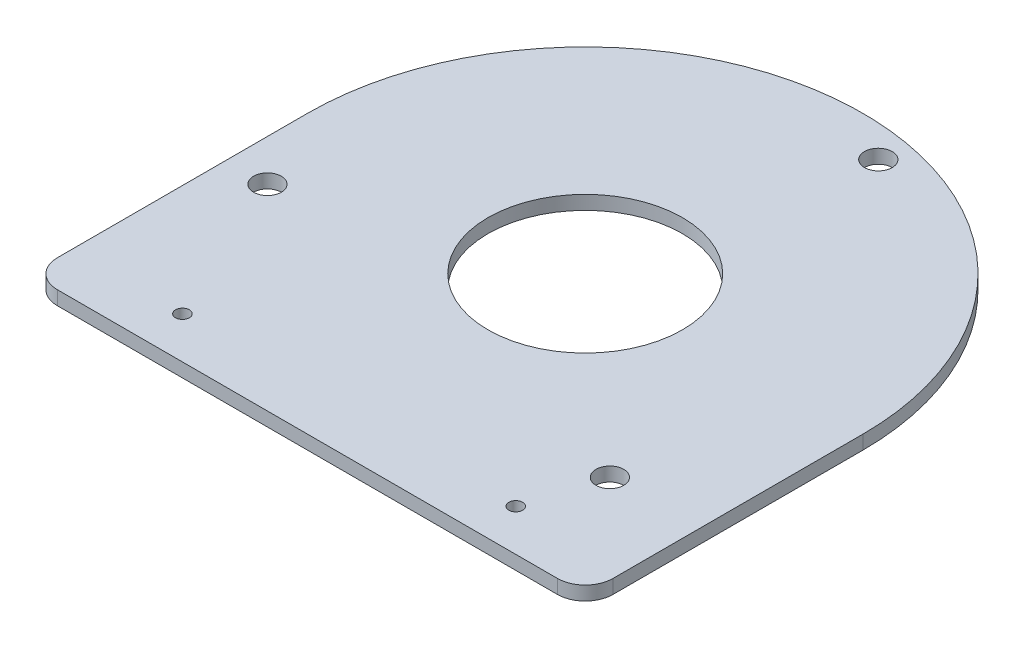
from build123d import *

# Parameters (mm, degrees)
SKETCH1_R           = 44.45
SKETCH1_R_2         = 6.35
SKETCH1_R_3         = 3.175
BOSS_EXTRUDE1_DEPTH = 6.35
SKETCH6_R           = 14.2875
SKETCH6_R_2         = 11.176
CUT_EXTRUDE1_DEPTH  = 28.448


with BuildPart() as part:
    # Sketch1 → Boss-Extrude1 (new body)
    with BuildSketch(Plane(origin=(0, 0, 0), x_dir=(1, 0, 0), z_dir=(0, 1, 0))):
        with BuildLine():
            Line((127, 0), (127, -114.3))
            ThreePointArc((127, -114.3), (123.280256121, -123.280256121), (114.3, -127))
            Line((114.3, -127), (-114.3, -127))
            ThreePointArc((-114.3, -127), (-123.280256121, -123.280256121), (-127, -114.3))
            Line((-127, -114.3), (-127, 0))
            ThreePointArc((-127, 0), (0, 127), (127, 0))
        make_face()
        Circle(SKETCH1_R, mode=Mode.SUBTRACT)
        with Locations((-108.072773191, -37.212440054)):
            Circle(SKETCH1_R_2, mode=Mode.SUBTRACT)
        with Locations((21.809468172, 112.199987068)):
            Circle(SKETCH1_R_2, mode=Mode.SUBTRACT)
        with Locations((86.263305019, -74.987547014)):
            Circle(SKETCH1_R_2, mode=Mode.SUBTRACT)
        with Locations((-76.2, -107.95)):
            Circle(SKETCH1_R_3, mode=Mode.SUBTRACT)
        with Locations((76.2, -107.95)):
            Circle(SKETCH1_R_3, mode=Mode.SUBTRACT)
    extrude(amount=BOSS_EXTRUDE1_DEPTH)

    # Sketch6 → Cut-Extrude1 (cut)
    with BuildSketch(Plane(origin=(0, 0, 0), x_dir=(1, 0, 0), z_dir=(0, 1, 0))):
        with Locations((174.752, 0)):
            Circle(SKETCH6_R)
        with Locations((174.752, 0)):
            Circle(SKETCH6_R_2, mode=Mode.SUBTRACT)
    extrude(amount=CUT_EXTRUDE1_DEPTH, mode=Mode.SUBTRACT)


solid = part.part
